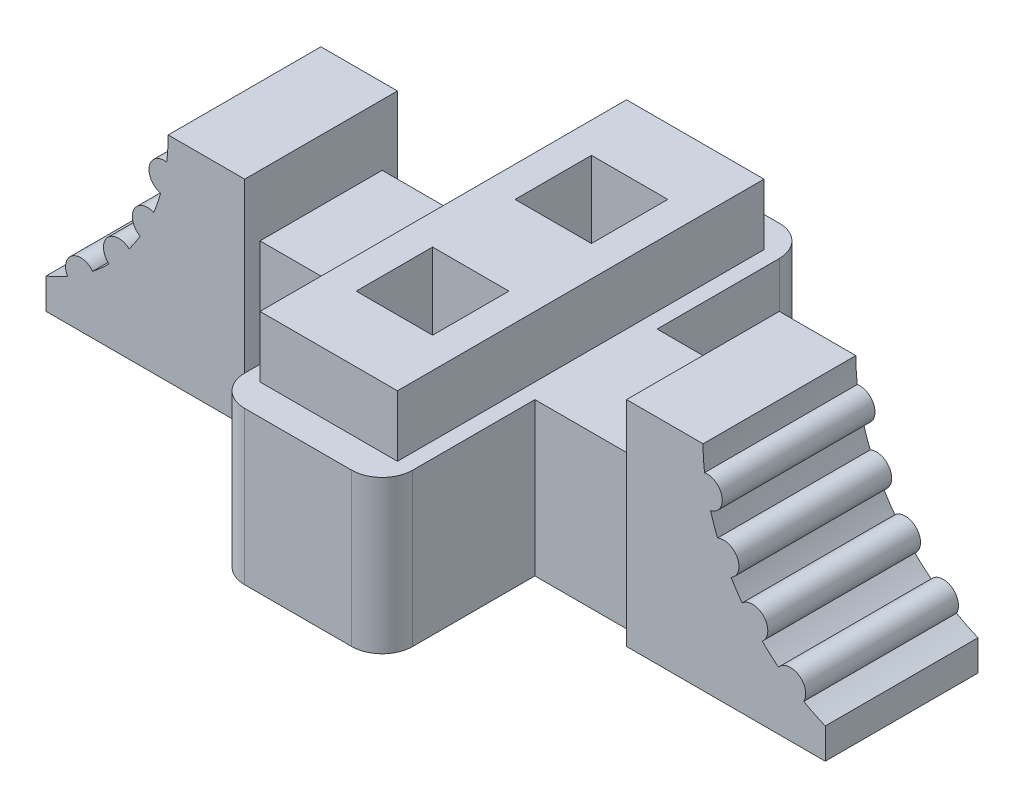
from build123d import *

# Parameters (mm, degrees)
SKETCH1_W           = 11
SKETCH1_H           = 28
BOSS_EXTRUDE1_DEPTH = 10
SKETCH2_R           = 3
CUT_EXTRUDE1_DEPTH  = 5
SKETCH3_W           = 5
SKETCH3_H           = 5
CUT_EXTRUDE2_DEPTH  = 1
FILLET1_R           = 2
BOSS_EXTRUDE2_DEPTH = 10
BOSS_EXTRUDE3_DEPTH = 5
SKETCH6_W           = 9
SKETCH6_H           = 24
SKETCH6_W_2         = 5
SKETCH6_H_2         = 5
BOSS_EXTRUDE4_DEPTH = 4


with BuildPart() as part:
    # Sketch1 → Boss-Extrude1 (new body)
    with BuildSketch(Plane(origin=(0, 0, 0), x_dir=(1, 0, 0), z_dir=(0, 1, 0))):
        with Locations((5.5, 14)):
            Rectangle(SKETCH1_W, SKETCH1_H)
    extrude(amount=BOSS_EXTRUDE1_DEPTH)

    # Sketch2 → Cut-Extrude1 (cut)
    with BuildSketch(Plane.XZ):
        with Locations(Location((5.5, -6, 0), (0, 0, 270))):  # turned: the seam where the file's is
            Circle(SKETCH2_R)
        with Locations(Location((5.5, -22, 0), (0, 0, 90))):  # turned: the seam where the file's is
            Circle(SKETCH2_R)
    extrude(amount=-CUT_EXTRUDE1_DEPTH, mode=Mode.SUBTRACT)

    # Sketch3 → Cut-Extrude2 (cut)
    with BuildSketch(Plane(origin=(0, 10, 0), x_dir=(1, 0, 0), z_dir=(0, 1, 0))):
        with Locations((5.5, 8.8)):
            Rectangle(SKETCH3_W, SKETCH3_H)
        with Locations((5.5, 19.2)):
            Rectangle(SKETCH3_W, SKETCH3_H)
    extrude(amount=-CUT_EXTRUDE2_DEPTH, mode=Mode.SUBTRACT)

    # Fillet1
    fillet1_edges = [part.edges().sort_by_distance(p)[0] for p in [
        (0, 5, -28),
        (11, 5, -28),
        (11, 5, 0),
        (0, 5, 0),
    ]]
    fillet(fillet1_edges, radius=FILLET1_R)

    # Sketch4 → Boss-Extrude2 (add)
    with BuildSketch(Plane(origin=(0, 10, 0), x_dir=(1, 0, 0), z_dir=(0, 1, 0))):
        Polygon((-7, 10), (3, 10), (3, 11.3), (8, 11.3), (8, 10), (18, 10), (18, 18), (8, 18), (8, 16.7), (3, 16.7), (3, 18), (-7, 18), align=None)
    extrude(amount=-BOSS_EXTRUDE2_DEPTH)

    # Sketch5 → Boss-Extrude3 (add, symmetric)
    with BuildSketch(Plane(origin=(0, 0, -14), x_dir=(-1, 0, 0), z_dir=(0, 0, -1))):
        with BuildLine():
            Line((-18, 10), (-18, 14))
            Line((-18, 14), (-23.009639132, 14))
            ThreePointArc((-23.009639132, 14), (-23.034060421, 13.203534611), (-23.107232535, 12.410061639))
            ThreePointArc((-23.107232535, 12.410061639), (-24.247773279, 11.621237367), (-23.503399625, 10.451201135))
            ThreePointArc((-23.503399625, 10.451201135), (-23.712034257, 9.784680991), (-23.956162944, 9.130327344))
            ThreePointArc((-23.956162944, 9.130327344), (-25.254024229, 8.659499735), (-24.844635532, 7.340968944))
            ThreePointArc((-24.844635532, 7.340968944), (-25.19276603, 6.789226373), (-25.568138069, 6.255643632))
            ThreePointArc((-25.568138069, 6.255643632), (-27.002153814, 6.177218324), (-26.878916821, 4.74635693))
            ThreePointArc((-26.878916821, 4.74635693), (-27.400685234, 4.259059964), (-27.948418079, 3.801141479))
            ThreePointArc((-27.948418079, 3.801141479), (-29.288657634, 4.007780534), (-29.602553888, 2.688534194))
            ThreePointArc((-29.602553888, 2.688534194), (-30.295715938, 2.323053407), (-31.009639132, 2))
            Line((-31.009639132, 2), (-31.009639132, 0))
            Line((-31.009639132, 0), (-18, 0))
            Line((-18, 0), (-18, 10))
        make_face()
    boss_extrude3 = extrude(amount=BOSS_EXTRUDE3_DEPTH, both=True)

    # Mirror1: Boss-Extrude3 across plane
    add(boss_extrude3.mirror(Plane.ZY.offset(-5.5)))

    # Sketch6 → Boss-Extrude4 (add)
    with BuildSketch(Plane(origin=(0, 10, 0), x_dir=(1, 0, 0), z_dir=(0, 1, 0))):
        with Locations((5.5, 14)):
            Rectangle(SKETCH6_W, SKETCH6_H)
        with Locations((5.5, 19.2)):
            Rectangle(SKETCH6_W_2, SKETCH6_H_2, mode=Mode.SUBTRACT)
        with Locations((5.5, 8.8)):
            Rectangle(SKETCH6_W_2, SKETCH6_H_2, mode=Mode.SUBTRACT)
    extrude(amount=BOSS_EXTRUDE4_DEPTH)


solid = part.part
